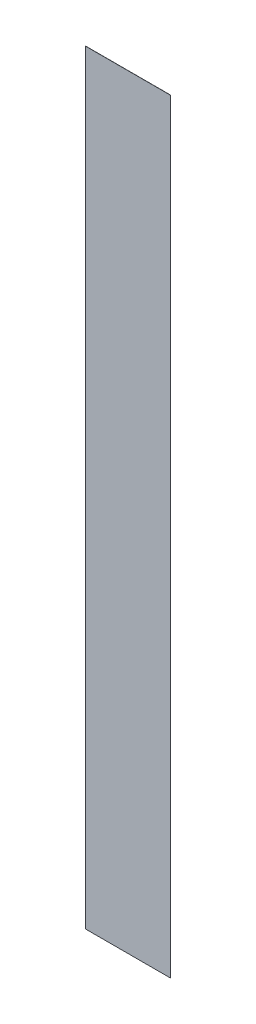
from build123d import *

# Parameters (mm, degrees)
SKETCH1_W           = 20
SKETCH1_H           = 180
BOSS_EXTRUDE1_DEPTH = 0.04


with BuildPart() as part:
    # Sketch1 → Boss-Extrude1 (new body)
    with BuildSketch(Plane.XY):
        with Locations((3.228699552, -87.791479821)):
            Rectangle(SKETCH1_W, SKETCH1_H)
    extrude(amount=BOSS_EXTRUDE1_DEPTH)


solid = part.part
